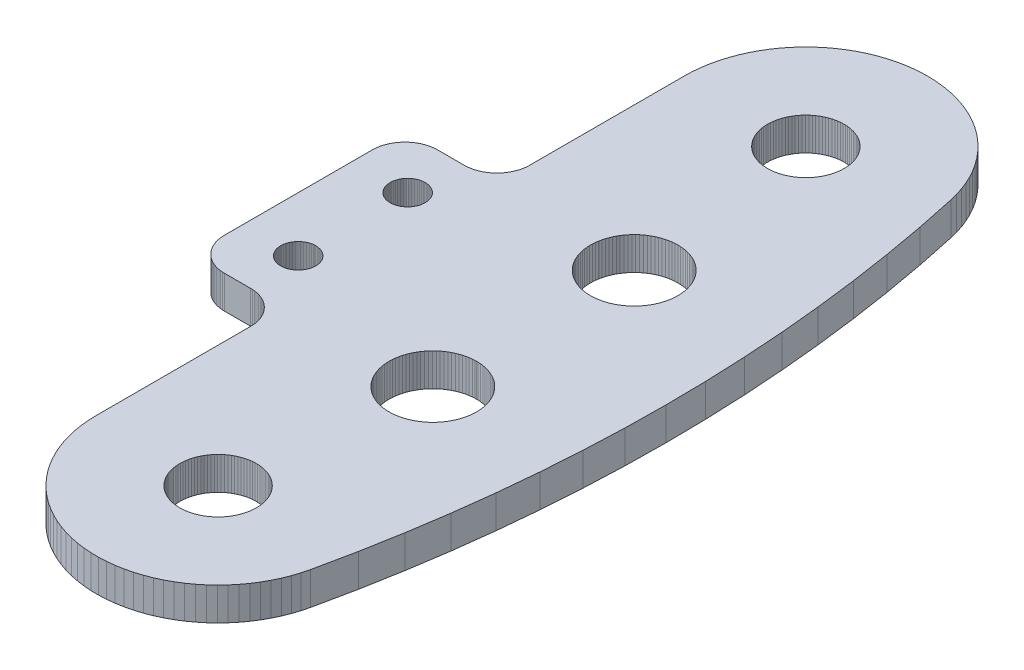
from build123d import *

# Parameters (mm, degrees)
BOSS_EXTRUDE1_DEPTH = 3.000000026


with BuildPart() as part:
    # Sketch1 → Boss-Extrude1 (new body)
    with BuildSketch(Plane(origin=(0, 3.000000026, 0), x_dir=(1, 0, 0), z_dir=(0, 1, 0))):
        Polygon((19.729751557, -0.001746714), (19.023086399, -0.011593216), (18.318472285, -0.06629965), (17.618753473, -0.165635033), (16.926757456, -0.309208191), (16.765635194, -0.353473067), (16.24527191, -0.496431687), (15.577052887, -0.726551038), (14.92479585, -0.998639607), (14.291132716, -1.311601982), (13.678622758, -1.664171619), (13.089738635, -2.054921728), (12.52685615, -2.48228396), (11.992249589, -2.944526053), (11.488074964, -3.439785358), (11.315639882, -3.632167), (11.154652573, -3.811776638), (11.016366072, -3.966059536), (10.579030961, -4.521224648), (10.177833028, -5.103044212), (9.814391844, -5.70916757), (9.490175173, -6.337143481), (9.206491522, -6.984444335), (8.964484558, -7.648451254), (8.765134029, -8.326485753), (8.609241806, -9.01581347), (8.497438394, -9.713647887), (8.430176415, -10.417172685), (8.407725021, -11.123551056), (8.407725021, -25.123551488), (8.408274502, -25.308668613), (8.397405036, -25.493469089), (8.375158533, -25.677246973), (8.341619745, -25.859303772), (8.296916261, -26.038944721), (8.241217583, -26.215484366), (8.174736984, -26.388254017), (8.097726852, -26.55659616), (8.010480553, -26.71986632), (7.913329639, -26.877444237), (7.806645241, -27.028732002), (7.690833416, -27.173150331), (7.566334214, -27.310151607), (7.43362261, -27.439210564), (7.29320338, -27.559841052), (7.145611104, -27.671581134), (6.9914083, -27.774006128), (6.831182167, -27.866723016), (6.665542256, -27.94938162), (6.495119072, -28.021669015), (6.320562679, -28.083305806), (6.142536644, -28.134059161), (5.961719435, -28.173737228), (5.778798833, -28.202185407), (5.594472401, -28.219297528), (5.409440957, -28.225008398), (3.000000026, -28.225008398), (2.811628394, -28.230929747), (2.623999957, -28.248665854), (2.437856048, -28.278147802), (2.253930317, -28.319260105), (2.072948962, -28.371840715), (1.895626308, -28.435681015), (1.722662128, -28.510529548), (1.554738963, -28.59608829), (1.392519567, -28.692025691), (1.236644224, -28.797958046), (1.087728073, -28.913469985), (0.946358661, -29.038103297), (0.813094142, -29.171368107), (0.688460248, -29.312737286), (0.572949008, -29.461653903), (0.467016216, -29.617529362), (0.37107995, -29.779747128), (0.28551885, -29.947672039), (0.210670536, -30.120637268), (0.146830454, -30.297959223), (0.094250514, -30.478939414), (0.053138247, -30.662864447), (0.023655895, -30.849009752), (0.005919815, -31.036637723), (0, -31.22500889), (0, -44.725008309), (0.005919815, -44.913381338), (0.023655895, -45.101009309), (0.053138247, -45.287154615), (0.094250514, -45.471079648), (0.146830454, -45.652061701), (0.210670536, -45.829381794), (0.28551885, -46.002347022), (0.37107995, -46.170271933), (0.467016216, -46.332489699), (0.572949008, -46.488367021), (0.688460248, -46.637281775), (0.813094142, -46.778649092), (0.946358661, -46.911917627), (1.087728073, -47.036550939), (1.236644224, -47.152061015), (1.392519567, -47.25799337), (1.554738963, -47.353930771), (1.722662128, -47.439489514), (1.895626308, -47.514338046), (2.072948962, -47.578178346), (2.253930317, -47.630757093), (2.437856048, -47.671869397), (2.623999957, -47.701351345), (2.811628394, -47.719091177), (3.000000026, -47.725010663), (5.409440957, -47.725010663), (5.594472401, -47.730721533), (5.778798833, -47.747835517), (5.961719435, -47.776281834), (6.142536644, -47.815959901), (6.320562679, -47.866713256), (6.495119072, -47.928348184), (6.665542256, -48.000637442), (6.831182167, -48.083297908), (6.9914083, -48.176012933), (7.145611104, -48.278436065), (7.29320338, -48.390179873), (7.43362261, -48.510808498), (7.566334214, -48.639867455), (7.690833416, -48.776868731), (7.806645241, -48.92128706), (7.913329639, -49.072574824), (8.010480553, -49.230150878), (8.097726852, -49.393422902), (8.174736984, -49.561765045), (8.241217583, -49.734532833), (8.296916261, -49.91107434), (8.341619745, -50.090715289), (8.375158533, -50.272770226), (8.397405036, -50.456549972), (8.408274502, -50.641350448), (8.407725021, -50.826467574), (8.407725021, -64.826466143), (8.430176415, -65.532848239), (8.497438394, -66.236369312), (8.609241806, -66.934205592), (8.765134029, -67.623533309), (8.964484558, -68.301565945), (9.206491522, -68.965576589), (9.490175173, -69.612875581), (9.814391844, -70.240855217), (10.177833028, -70.84697485), (10.579030961, -71.428790689), (11.016366072, -71.983963251), (11.488073505, -72.510235012), (11.992248707, -73.005497456), (12.526855804, -73.467724025), (13.089738786, -73.895096779), (13.678623363, -74.285849929), (14.291133732, -74.638411403), (14.924797229, -74.951380491), (15.577054583, -75.223460793), (16.245273873, -75.453579426), (16.765637323, -75.596541166), (16.926759342, -75.640806928), (17.618754571, -75.784380162), (18.318472837, -75.883719389), (19.02308665, -75.938429695), (19.729751754, -75.948287529), (20.43561644, -75.913240704), (21.137828995, -75.833445651), (21.833560059, -75.70921526), (22.519997031, -75.541056138), (23.194370151, -75.329646256), (23.85395622, -75.0758424), (24.265645826, -74.886587509), (24.496092098, -74.780650698), (25.118177428, -74.445265685), (25.717710962, -74.071056131), (26.292271291, -73.659527103), (26.839537591, -73.212347574), (27.357302663, -72.731313178), (27.843476656, -72.218376006), (28.296094519, -71.675592457), (28.713330904, -71.105167938), (29.093502022, -70.509397261), (29.435073102, -69.890686992), (29.736665833, -69.251533104), (29.997060233, -68.59452097), (30.215205822, -67.922295568), (30.390225347, -67.237576376), (31.140119809, -63.627666169), (31.79115401, -59.998624782), (32.342839989, -56.353156786), (32.355500269, -56.25067008), (32.79485993, -52.693993234), (33.146799002, -49.023847156), (33.39837136, -45.345463756), (33.524255601, -42.274949991), (33.549402361, -41.66158114), (33.599778363, -37.974948571), (33.549369473, -34.28841062), (33.398350444, -30.604527513), (33.225360436, -28.0750449), (33.146787533, -26.926141605), (32.7948534, -23.255998779), (32.355498524, -19.699319479), (32.342838615, -19.596834591), (31.791165836, -15.951364597), (31.140144775, -12.32231899), (30.390263384, -8.712404205), (30.215246339, -8.027684379), (29.997103184, -7.35546005), (29.736711163, -6.698443248), (29.435120746, -6.059291527), (29.093551907, -5.440580488), (28.713382946, -4.844808434), (28.296148627, -4.274378679), (27.910338383, -3.811714844), (27.843530637, -3.731598961), (27.357345107, -3.218668999), (26.839569216, -2.737649973), (26.292292859, -2.290479028), (25.717723274, -1.878966647), (25.118181324, -1.504770579), (24.496088451, -1.16939944), (24.265639796, -1.063464203), (23.85395123, -0.87421456), (23.194366555, -0.620403296), (22.519994597, -0.40898971), (21.833558549, -0.240826817), (21.137828167, -0.116596328), (20.43561605, -0.036793692), align=None)
        Polygon((19.863956049, -7.639366676), (20.084264129, -7.667483304), (20.302346348, -7.709513892), (20.517323538, -7.765292664), (20.728331431, -7.834594239), (20.934516936, -7.917139221), (21.135053038, -8.012594197), (21.32913135, -8.120577325), (21.515969559, -8.240650882), (21.694817021, -8.372332443), (21.864951029, -8.515093018), (22.025689855, -8.668357049), (22.176383435, -8.831506137), (22.316426411, -9.003884633), (22.4452544, -9.184797768), (22.562349587, -9.373519112), (22.667238861, -9.56928498), (22.759499401, -9.771311198), (22.838762402, -9.978780065), (22.904707491, -10.190860842), (22.957068309, -10.406694849), (22.995634377, -10.625415955), (23.020251095, -10.846143131), (23.030819744, -11.067987893), (23.027324649, -11.290126486), (23.009723099, -11.511524101), (22.978112604, -11.731358867), (22.932625419, -11.948746029), (22.873442226, -12.162810144), (22.800799585, -12.372690673), (22.714993663, -12.577541975), (22.616367192, -12.776537038), (22.505316921, -12.968876791), (22.382293614, -13.153786376), (22.247789015, -13.330520738), (22.102345157, -13.49836835), (21.946550642, -13.656653076), (21.781029459, -13.804737894), (21.606450301, -13.942026764), (21.423513528, -14.067968345), (21.232958611, -14.182052279), (21.035552965, -14.28382036), (20.832088215, -14.372864672), (20.623385791, -14.448823869), (20.410285747, -14.511394344), (20.193646764, -14.560322784), (19.974340563, -14.595413616), (19.753251899, -14.616523422), (19.531267393, -14.623568388), (19.30928484, -14.616520582), (19.088194584, -14.595407948), (18.868888831, -14.56031431), (18.652250474, -14.511383099), (18.439151231, -14.448809898), (18.230451641, -14.372848031), (18.026988031, -14.283801115), (17.829581823, -14.18203051), (17.639028366, -14.067944138), (17.456095067, -13.942000216), (17.281515803, -13.804709113), (17.115996514, -13.656622177), (16.960204024, -13.498335459), (16.814764176, -13.330485986), (16.765637323, -13.265933841), (16.68026112, -13.153750449), (16.557237133, -12.968840078), (16.446189955, -12.776499614), (16.347564757, -12.57750392), (16.261758283, -12.372652069), (16.189118847, -12.162771076), (16.12993516, -11.948706582), (16.084449366, -11.731319129), (16.052840278, -11.511484161), (16.035240144, -11.290086433), (16.031717882, -11.068020016), (16.042284667, -10.846175253), (16.066901386, -10.625448078), (16.105467454, -10.406726971), (16.157828271, -10.190892965), (16.22377336, -9.978812188), (16.303036362, -9.771343321), (16.395298764, -9.569317102), (16.500188038, -9.373551235), (16.617281362, -9.184829891), (16.746109352, -9.003916755), (16.765637323, -8.97987932), (16.886150532, -8.831536802), (17.036844001, -8.66838589), (17.197579109, -8.515119914), (17.367715115, -8.37235728), (17.546557258, -8.240673554), (17.733395878, -8.120597737), (17.92747102, -8.012612261), (18.128005966, -7.917154858), (18.334192335, -7.834607381), (18.545197527, -7.765303252), (18.760174042, -7.709521879), (18.978255753, -7.667488652), (19.198563493, -7.639369358), (19.420212507, -7.625281353), (19.642308727, -7.625281353), align=None, mode=Mode.SUBTRACT)
        Polygon((3.89587367, -31.817033887), (3.971539903, -31.749337912), (4.051347263, -31.686577946), (4.134974908, -31.629003584), (4.222084768, -31.57684952), (4.312328063, -31.530328095), (4.40534018, -31.489621848), (4.500746261, -31.454894692), (4.598163068, -31.426291913), (4.697198048, -31.403921545), (4.797452129, -31.387880445), (4.898521584, -31.378231943), (4.999999888, -31.375009567), (5.101478193, -31.378231943), (5.202548113, -31.387880445), (5.302802194, -31.403921545), (5.401836708, -31.426291913), (5.499253981, -31.454894692), (5.594660062, -31.489621848), (5.687671714, -31.530328095), (5.777915008, -31.57684952), (5.865025334, -31.629003584), (5.948652513, -31.686577946), (6.028460339, -31.749337912), (6.104126573, -31.817033887), (6.175346673, -31.889393926), (6.241834257, -31.96612373), (6.30332157, -32.046917826), (6.359560881, -32.131448388), (6.410325412, -32.219376415), (6.455411203, -32.310344279), (6.494636647, -32.403990626), (6.527843419, -32.499935478), (6.55489834, -32.597795129), (6.575692445, -32.697170973), (6.590141449, -32.797668129), (6.598187611, -32.898880541), (6.599798799, -33.000394702), (6.594967563, -33.10180828), (6.583714392, -33.202715218), (6.56608399, -33.30270201), (6.542147603, -33.401366323), (6.512001157, -33.498317003), (6.475766655, -33.593162894), (6.43358985, -33.685516566), (6.385640707, -33.775009215), (6.332111545, -33.861283213), (6.273218896, -33.943984658), (6.209199317, -34.022785723), (6.140310783, -34.09736976), (6.066830363, -34.167431295), (5.989054218, -34.232698381), (5.907295737, -34.292891622), (5.821883678, -34.347783774), (5.73316263, -34.397147596), (5.641488824, -34.440781921), (5.54723246, -34.478519112), (5.450772122, -34.510198981), (5.352496635, -34.535698593), (5.252802279, -34.55491364), (5.152089521, -34.567765892), (5.050764885, -34.574203193), (4.999999888, -34.575007856), (4.949235357, -34.574203193), (4.847910255, -34.567765892), (4.747197963, -34.55491364), (4.647503607, -34.535698593), (4.549228121, -34.510198981), (4.452767782, -34.478519112), (4.358510952, -34.440781921), (4.266837612, -34.397147596), (4.178116098, -34.347783774), (4.092704039, -34.292891622), (4.010945093, -34.232698381), (3.933169413, -34.167431295), (3.859689226, -34.09736976), (3.790800925, -34.022785723), (3.726781113, -33.943984658), (3.667888232, -33.861283213), (3.614359302, -33.775009215), (3.566409927, -33.685516566), (3.524233121, -33.593162894), (3.48799862, -33.498317003), (3.457852639, -33.401366323), (3.433916019, -33.30270201), (3.416285617, -33.202715218), (3.405032447, -33.10180828), (3.400201444, -33.000394702), (3.401812166, -32.898880541), (3.40985856, -32.797668129), (3.424307564, -32.697170973), (3.445101436, -32.597795129), (3.472156357, -32.499935478), (3.505363362, -32.403990626), (3.544588806, -32.310344279), (3.589674598, -32.219376415), (3.640439361, -32.131448388), (3.696678439, -32.046917826), (3.758165753, -31.96612373), (3.824653337, -31.889393926), align=None, mode=Mode.SUBTRACT)
        Polygon((3.726781113, -43.943986297), (3.667888232, -43.861281127), (3.614359302, -43.775010854), (3.566409927, -43.685518205), (3.524233121, -43.593160808), (3.48799862, -43.498318642), (3.457852639, -43.401367962), (3.433916019, -43.302699924), (3.416285617, -43.202713132), (3.405032447, -43.101809919), (3.400201444, -43.000396341), (3.401812166, -42.898878455), (3.40985856, -42.797669768), (3.424307564, -42.697172612), (3.445101436, -42.597796768), (3.472156357, -42.499937117), (3.505363362, -42.403992265), (3.544588806, -42.310345918), (3.562101861, -42.275011539), (3.589677143, -42.219375591), (3.640445931, -42.131453612), (3.696688876, -42.046925623), (3.758179887, -41.966134341), (3.824670982, -41.889407579), (3.895894626, -41.8170508), (3.971563957, -41.749358287), (4.051374189, -41.686598248), (4.135004468, -41.629031438), (4.222116715, -41.57688136), (4.312362138, -41.530360339), (4.405376118, -41.489658348), (4.500783788, -41.454939283), (4.598201904, -41.426340962), (4.697237907, -41.403975126), (4.797492722, -41.387938613), (4.898562618, -41.378291011), (5.00004107, -41.375077004), (5.101519227, -41.378300298), (5.202588705, -41.38795715), (5.302842052, -41.404002838), (5.401875543, -41.426377737), (5.499291507, -41.454984974), (5.594695999, -41.489712771), (5.687705787, -41.530423274), (5.777946953, -41.576952554), (5.865054892, -41.629110604), (5.948679437, -41.686685067), (6.02848439, -41.74945241), (6.104147527, -41.817151847), (6.175364315, -41.889515145), (6.241848388, -41.966247992), (6.303332005, -42.047044901), (6.359567447, -42.131578037), (6.410327955, -42.219504661), (6.437898145, -42.275143133), (6.455407966, -42.310479114), (6.49462484, -42.404129051), (6.527822831, -42.500076942), (6.554868796, -42.597939068), (6.575653806, -42.697316815), (6.590093613, -42.797815293), (6.598130512, -42.899024716), (6.599732409, -43.000542749), (6.594967563, -43.101809919), (6.583714392, -43.202713132), (6.56608399, -43.302699924), (6.542147603, -43.401367962), (6.512001157, -43.498318642), (6.475766655, -43.593160808), (6.43358985, -43.685518205), (6.385640707, -43.775010854), (6.332111545, -43.861281127), (6.273218896, -43.943986297), (6.209199317, -44.022787362), (6.140310783, -44.097371399), (6.066830363, -44.167432934), (5.989054218, -44.232696295), (5.907295737, -44.292893261), (5.821883678, -44.347781688), (5.73316263, -44.39714551), (5.641488824, -44.44078356), (5.54723246, -44.478517026), (5.450772122, -44.510196894), (5.352496635, -44.535696507), (5.252802279, -44.554911554), (5.152089521, -44.567763805), (5.050764885, -44.574204832), (4.999999888, -44.575009495), (4.949235357, -44.574204832), (4.847910255, -44.567763805), (4.747197963, -44.554911554), (4.647503607, -44.535696507), (4.549228121, -44.510196894), (4.452767782, -44.478517026), (4.358510952, -44.44078356), (4.266837612, -44.39714551), (4.178116098, -44.347781688), (4.092704039, -44.292893261), (4.010945093, -44.232696295), (3.933169413, -44.167432934), (3.859689226, -44.097371399), (3.790800925, -44.022787362), align=None, mode=Mode.SUBTRACT)
        Polygon((20.99362947, -24.807190523), (21.246304736, -24.78306368), (21.50000073, -24.775009602), (21.753694862, -24.78306368), (22.006370127, -24.807190523), (22.257005796, -24.847295135), (22.504592314, -24.903215468), (22.748133168, -24.97472614), (22.986650467, -25.06153658), (23.219179362, -25.163304061), (23.444786668, -25.279611349), (23.662563413, -25.40999651), (23.871632293, -25.553928688), (24.071149528, -25.710832328), (24.260316044, -25.880072266), (24.265637621, -25.885481387), (24.438366294, -26.060972363), (24.604585022, -26.252798736), (24.758303538, -26.454782113), (24.898901582, -26.666108519), (25.025812909, -26.885924861), (25.138527155, -27.113348246), (25.236591697, -27.347464114), (25.319609791, -27.587328106), (25.387246162, -27.831973508), (25.4381001, -28.075009584), (25.439230725, -28.080416843), (25.475353003, -28.331656009), (25.49546957, -28.584681451), (25.499496609, -28.838474303), (25.487385624, -29.091994141), (25.459255529, -29.344252541), (25.415183024, -29.594220096), (25.355345048, -29.840890976), (25.279981868, -30.083266798), (25.189398946, -30.320378984), (25.083961347, -30.551266405), (24.964090018, -30.775001456), (24.830271096, -30.990682613), (24.683041013, -31.197441874), (24.522993941, -31.394448493), (24.350776207, -31.580908974), (24.265637621, -31.662087888), (24.167075753, -31.756065786), (23.972636089, -31.919222325), (23.768238723, -32.069716603), (23.554708809, -32.206945121), (23.332906887, -32.330352813), (23.10372144, -32.439444214), (22.868080065, -32.53377974), (22.626930848, -32.612979412), (22.381242365, -32.676730305), (22.132005543, -32.724764198), (21.880224347, -32.756898552), (21.626912057, -32.772995532), (21.50000073, -32.775010914), (21.37308754, -32.772995532), (21.119775251, -32.756898552), (20.867994055, -32.724764198), (20.618757233, -32.676730305), (20.373070613, -32.612979412), (20.131919533, -32.53377974), (19.896278158, -32.439444214), (19.667094573, -32.330352813), (19.445290789, -32.206945121), (19.231760874, -32.069716603), (19.027363509, -31.919222325), (18.832923844, -31.756065786), (18.649224192, -31.580910087), (18.477004021, -31.394451857), (18.316952512, -31.19744733), (18.169719726, -30.990689993), (18.035897985, -30.775010586), (17.916025594, -30.551277101), (17.810583115, -30.320391059), (17.719997093, -30.083280057), (17.644630745, -29.840905219), (17.584789544, -29.594235122), (17.540713772, -29.344268143), (17.51258038, -29.092010111), (17.500502989, -28.838474303), (17.504530028, -28.584681451), (17.524646595, -28.331656009), (17.560768872, -28.080416843), (17.561899498, -28.075009584), (17.612753436, -27.831973508), (17.680391669, -27.587328106), (17.763407901, -27.347464114), (17.861472443, -27.113348246), (17.974186689, -26.885924861), (18.101098016, -26.666108519), (18.24169606, -26.454782113), (18.395414576, -26.252798736), (18.561633304, -26.060972363), (18.739683554, -25.880072266), (18.92885007, -25.710832328), (19.128369167, -25.553928688), (19.337436184, -25.40999651), (19.55521293, -25.279611349), (19.780820236, -25.163304061), (20.013350993, -25.06153658), (20.25186643, -24.97472614), (20.495407283, -24.903215468), (20.742995664, -24.847295135), align=None, mode=Mode.SUBTRACT)
        Polygon((21.50000073, -51.175009459), (21.246304736, -51.166955382), (20.99362947, -51.142826676), (20.742995664, -51.102723926), (20.495407283, -51.046803594), (20.25186643, -50.975292921), (20.013350993, -50.888482481), (19.780820236, -50.786715001), (19.55521293, -50.670407712), (19.337436184, -50.540022552), (19.128369167, -50.396092236), (18.92885007, -50.239186734), (18.739683554, -50.069946796), (18.561633304, -49.889046699), (18.395414576, -49.697220325), (18.24169606, -49.495235085), (18.101098016, -49.283910543), (17.974186689, -49.064092338), (17.861472443, -48.836670816), (17.763407901, -48.602554947), (17.680391669, -48.362690955), (17.612753436, -48.118047416), (17.560768872, -47.869600356), (17.524646595, -47.618363053), (17.504530028, -47.36533761), (17.500502989, -47.111544758), (17.51258038, -46.858008951), (17.540713772, -46.605750918), (17.584789544, -46.355783939), (17.644630745, -46.109113842), (17.719997093, -45.866739005), (17.810583115, -45.629628003), (17.916025594, -45.398741961), (18.035897985, -45.175008476), (18.169719726, -44.959329069), (18.316952512, -44.752571732), (18.477004021, -44.555567205), (18.649224192, -44.369108975), (18.832923844, -44.193953276), (19.027363509, -44.030796736), (19.231760874, -43.880302459), (19.445290789, -43.74307394), (19.667094573, -43.619666249), (19.896278158, -43.510574847), (20.131919533, -43.416239321), (20.373070613, -43.337039649), (20.618757233, -43.273288757), (20.867994055, -43.225254864), (21.119775251, -43.193120509), (21.37308754, -43.17702353), (21.50000073, -43.175008148), (21.626912057, -43.17702353), (21.880224347, -43.193120509), (22.132005543, -43.225254864), (22.381242365, -43.273288757), (22.626930848, -43.337039649), (22.868080065, -43.416239321), (23.10372144, -43.510574847), (23.332906887, -43.619666249), (23.554708809, -43.74307394), (23.768238723, -43.880302459), (23.972636089, -44.030796736), (24.167075753, -44.193953276), (24.265637621, -44.287931174), (24.350776207, -44.369110088), (24.522993941, -44.555570569), (24.683041013, -44.752577188), (24.830271096, -44.959336449), (24.964090018, -45.175017605), (25.083961347, -45.398752657), (25.189398946, -45.629640077), (25.279981868, -45.866752263), (25.355345048, -46.109128086), (25.415183024, -46.355798965), (25.459255529, -46.60576652), (25.487385624, -46.858024921), (25.499459702, -47.111560886), (25.49546957, -47.36533761), (25.475353003, -47.618363053), (25.439230725, -47.869600356), (25.387246162, -48.118047416), (25.319609791, -48.362690955), (25.236591697, -48.602554947), (25.138527155, -48.836670816), (25.025812909, -49.064092338), (24.898901582, -49.283910543), (24.758303538, -49.495235085), (24.604585022, -49.697220325), (24.438366294, -49.889046699), (24.265637621, -50.064537674), (24.260316044, -50.069946796), (24.071149528, -50.239186734), (23.871632293, -50.396092236), (23.662563413, -50.540022552), (23.444786668, -50.670407712), (23.219179362, -50.786715001), (22.986650467, -50.888482481), (22.748133168, -50.975292921), (22.504592314, -51.046803594), (22.257005796, -51.102723926), (22.006370127, -51.142826676), (21.753694862, -51.166955382), align=None, mode=Mode.SUBTRACT)
        Polygon((18.760253442, -61.412565363), (18.978337779, -61.370543904), (19.198647276, -61.342443968), (19.420297171, -61.328366092), (19.642393391, -61.328366092), (19.864040713, -61.34245514), (20.084348793, -61.370566181), (20.302431012, -61.412598631), (20.517408202, -61.468377403), (20.728416095, -61.537678978), (20.9346016, -61.620220236), (21.135137702, -61.715677074), (21.329216014, -61.823658339), (21.516054223, -61.943731896), (21.694901685, -62.075417182), (21.865035693, -62.218174032), (22.025774519, -62.371439925), (22.176468099, -62.534585289), (22.316511075, -62.706969372), (22.445339064, -62.88788437), (22.562434251, -63.076600126), (22.667323525, -63.272371582), (22.759584065, -63.474394075), (22.838847066, -63.681862942), (22.904792155, -63.893943719), (22.957152973, -64.109772137), (22.995719041, -64.328498832), (23.020335759, -64.549229733), (23.030904408, -64.77107077), (23.027324649, -64.993049024), (23.009723099, -65.214442914), (22.978112604, -65.434279543), (22.932625419, -65.651664842), (22.873442226, -65.865727094), (22.800799585, -66.075609485), (22.714993663, -66.28046265), (22.616367192, -66.479452126), (22.505316921, -66.671795604), (22.382293614, -66.856703326), (22.247789015, -67.033437688), (22.102345157, -67.201283438), (21.946550642, -67.359570026), (21.781029459, -67.507656707), (21.606450301, -67.644939988), (21.423513528, -67.770883433), (21.232958611, -67.884965504), (21.035552965, -67.986739172), (20.832088215, -68.075779759), (20.623385791, -68.151744544), (20.410285747, -68.214313157), (20.193646764, -68.263239734), (19.974340563, -68.298330566), (19.753251899, -68.319444097), (19.531267393, -68.326483476), (19.30928484, -68.319441257), (19.088194584, -68.298324898), (18.868888831, -68.26323126), (18.652250474, -68.214301912), (18.439151231, -68.151730573), (18.230451641, -68.075763118), (18.026988031, -67.986719928), (17.829581823, -67.884943734), (17.639028366, -67.770859225), (17.456095067, -67.644913441), (17.281515803, -67.507627926), (17.115996514, -67.359539127), (16.960204024, -67.201250546), (16.814764176, -67.033402936), (16.765637323, -66.968850791), (16.68026112, -66.856667399), (16.557237133, -66.67175889), (16.446189955, -66.479414701), (16.347564757, -66.280424595), (16.261758283, -66.075570881), (16.189118847, -65.865688026), (16.12993516, -65.651625395), (16.084449366, -65.434239805), (16.052840278, -65.214402974), (16.035240144, -64.993008971), (16.031717882, -64.770936966), (16.042284667, -64.549095929), (16.066901386, -64.328365028), (16.105467454, -64.109638333), (16.157828271, -63.893809915), (16.22377336, -63.681729138), (16.303036362, -63.474260271), (16.395298764, -63.272237778), (16.500188038, -63.076466322), (16.617281362, -62.887750566), (16.746109352, -62.706835568), (16.765637323, -62.682799995), (16.886159804, -62.534457559), (17.03686347, -62.371319792), (17.197608159, -62.218062), (17.367753087, -62.075313727), (17.546603461, -61.943637455), (17.733449585, -61.823573315), (17.927531476, -61.715601833), (18.12807239, -61.620155102), (18.334263917, -61.537624238), (18.54527344, -61.468333298), align=None, mode=Mode.SUBTRACT)
    extrude(amount=-BOSS_EXTRUDE1_DEPTH)


solid = part.part
